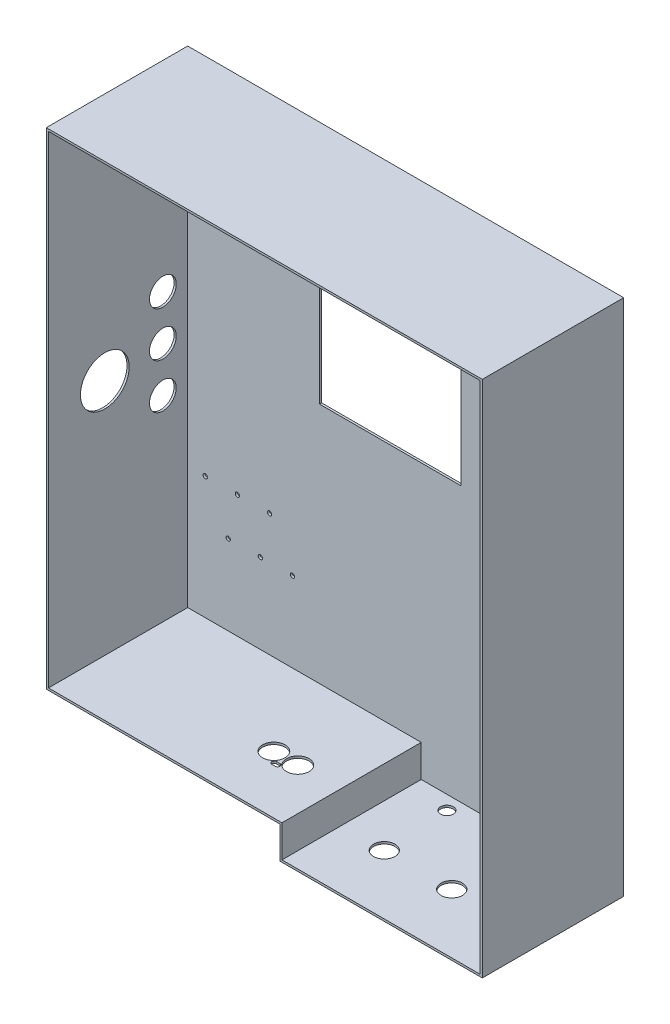
from build123d import *

# Parameters (mm, degrees)
DODANIE_WYCI_GNI_CIE1_DEPTH     = 130
SKORUPA1_T                      = 2
WYTNIJ_WYCI_GNI_CIE1_REACH      = 1414.162
SZKIC6_W                        = 132
SZKIC6_H                        = 206
OTWORY_USTALAJ_CE_12_0MM1_D     = 12
OTWORY_USTALAJ_CE_12_0MM1_DEPTH = 2
SZKIC10_R                       = 12.5
SZKIC10_R_2                     = 22.75
WYTNIJ_WYCI_GNI_CIE2_DEPTH      = 10
SZKIC8_R                        = 10
WYTNIJ_WYCI_GNI_CIE3_DEPTH      = 10
SZKIC11_R                       = 2
WYTNIJ_WYCI_GNI_CIE4_DEPTH      = 10
SZKIC12_R                       = 10.5
WYTNIJ_WYCI_GNI_CIE5_DEPTH      = 10


with BuildPart() as part:
    # Szkic1 → Dodanie-wyciągnięcie1 (new body)
    with BuildSketch(Plane.XY.offset(434.283231707)):
        Polygon((-977.291509632, 225), (-977.291509632, -255), (-1162.291509632, -255), (-1162.291509632, -225), (-1380.291509632, -225), (-1380.291509632, 225), align=None)
    extrude(amount=DODANIE_WYCI_GNI_CIE1_DEPTH)

    # Skorupa1
    skorupa1_openings = [part.faces().sort_by_distance(p)[0] for p in [
        (-1175.554752008, -7.126805778, 564.283231707),
    ]]
    offset(amount=SKORUPA1_T, openings=skorupa1_openings, kind=Kind.INTERSECTION)

    # Szkic6 → Wytnij-wyciągnięcie1 (cut, up to next)
    with BuildSketch(Plane(origin=(0, 0, 432.283231707), x_dir=(-1, 0, 0), z_dir=(0, 0, -1)), mode=Mode.PRIVATE) as wytnij_wyci_gni_cie1_sk1:
        with Locations((1191.291509632, 104)):
            Rectangle(SZKIC6_W, SZKIC6_H)
    wytnij_wyci_gni_cie1_tool1 = extrude(wytnij_wyci_gni_cie1_sk1.sketch, amount=-WYTNIJ_WYCI_GNI_CIE1_REACH, mode=Mode.PRIVATE) & part.part
    add(wytnij_wyci_gni_cie1_tool1.solids().sort_by_distance((-1191.29151, 104, 432.283232))[0], mode=Mode.SUBTRACT)

    # Otwory ustalające Ø12.0mm1
    with Locations(Plane(origin=(-1125.291509632, -257, 447.283231707), x_dir=(0, 0, -1), z_dir=(0, -1, 0))):
        with Locations((0, 0), (0, 40), (0, 80)):
            Hole(OTWORY_USTALAJ_CE_12_0MM1_D / 2, depth=OTWORY_USTALAJ_CE_12_0MM1_DEPTH)

    # Szkic10 → Wytnij-wyciągnięcie2 (cut)
    with BuildSketch(Plane.ZY.offset(1382.291509632)):
        with Locations((457.483231707, 42)):
            Circle(SZKIC10_R)
        with Locations((457.483231707, 0)):
            Circle(SZKIC10_R)
        with Locations((457.483231707, -42)):
            Circle(SZKIC10_R)
        with Locations((511.683231707, -3)):
            Circle(SZKIC10_R_2)
    extrude(amount=-WYTNIJ_WYCI_GNI_CIE2_DEPTH, mode=Mode.SUBTRACT)

    # Szkic8 → Wytnij-wyciągnięcie3 (cut)
    with BuildSketch(Plane.XZ.offset(257)):
        with Locations((-1122.291509632, 508.783231707)):
            Circle(SZKIC8_R)
        with Locations((-1059.291509632, 508.783231707)):
            Circle(SZKIC8_R)
    extrude(amount=-WYTNIJ_WYCI_GNI_CIE3_DEPTH, mode=Mode.SUBTRACT)

    # Szkic11 → Wytnij-wyciągnięcie4 (cut)
    with BuildSketch(Plane(origin=(0, 0, 432.283231707), x_dir=(-1, 0, 0), z_dir=(0, 0, -1))):
        with Locations((1363.891509632, -110.6)):
            Circle(SZKIC11_R)
        with Locations((1342.491509632, -150.3)):
            Circle(SZKIC11_R)
        with Locations((1312.491509632, -150.3)):
            Circle(SZKIC11_R)
        with Locations((1333.891509632, -110.6)):
            Circle(SZKIC11_R)
        with Locations((1282.491509632, -150.3)):
            Circle(SZKIC11_R)
        with Locations((1303.891509632, -110.6)):
            Circle(SZKIC11_R)
    extrude(amount=-WYTNIJ_WYCI_GNI_CIE4_DEPTH, mode=Mode.SUBTRACT)

    # Szkic12 → Wytnij-wyciągnięcie5 (cut)
    with BuildSketch(Plane(origin=(0, -225, 0), x_dir=(1, 0, 0), z_dir=(0, 1, 0))):
        with Locations(Location((-1201.521509632, -510.283231707, 0), (0, 0, 180))):
            Circle(SZKIC12_R)
        with Locations(Location((-1223.871509632, -510.283231707, 0), (0, 0, 180))):
            Circle(SZKIC12_R)
        with BuildLine():
            Line((-1211.196509632, -521.783231707), (-1214.196509632, -521.783231707))
            ThreePointArc((-1214.196509632, -521.783231707), (-1216.446509632, -519.533231707), (-1214.196509632, -517.283231707))
            Line((-1214.196509632, -517.283231707), (-1211.196509632, -517.283231707))
            ThreePointArc((-1211.196509632, -517.283231707), (-1208.946509632, -519.533231707), (-1211.196509632, -521.783231707))
        make_face()
    extrude(amount=-WYTNIJ_WYCI_GNI_CIE5_DEPTH, mode=Mode.SUBTRACT)


solid = part.part
